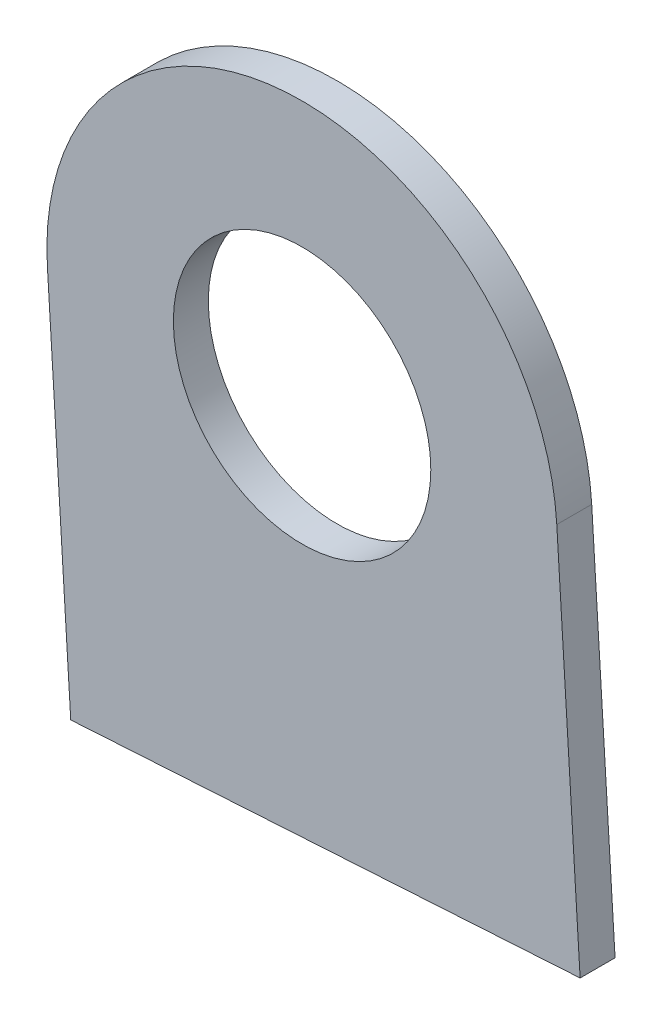
from build123d import *

# Parameters (mm, degrees)
SKETCH2_R           = 11.05
BOSS_EXTRUDE1_DEPTH = 3


with BuildPart() as part:
    # Sketch2 → Boss-Extrude1 (new body)
    with BuildSketch(Plane.XY.offset(777.361907162)):
        with BuildLine():
            Line((-21.864371204, -1.339746134), (-19.859932286, -34.051761818))
            Line((-19.859932286, -34.051761818), (23.868810121, -31.37226955))
            Line((23.868810121, -31.37226955), (21.864371204, 1.339746134))
            ThreePointArc((21.864371204, 1.339746134), (-1.339746134, 21.864371204), (-21.864371204, -1.339746134))
        make_face()
        Circle(SKETCH2_R, mode=Mode.SUBTRACT)
    extrude(amount=BOSS_EXTRUDE1_DEPTH)


solid = part.part
